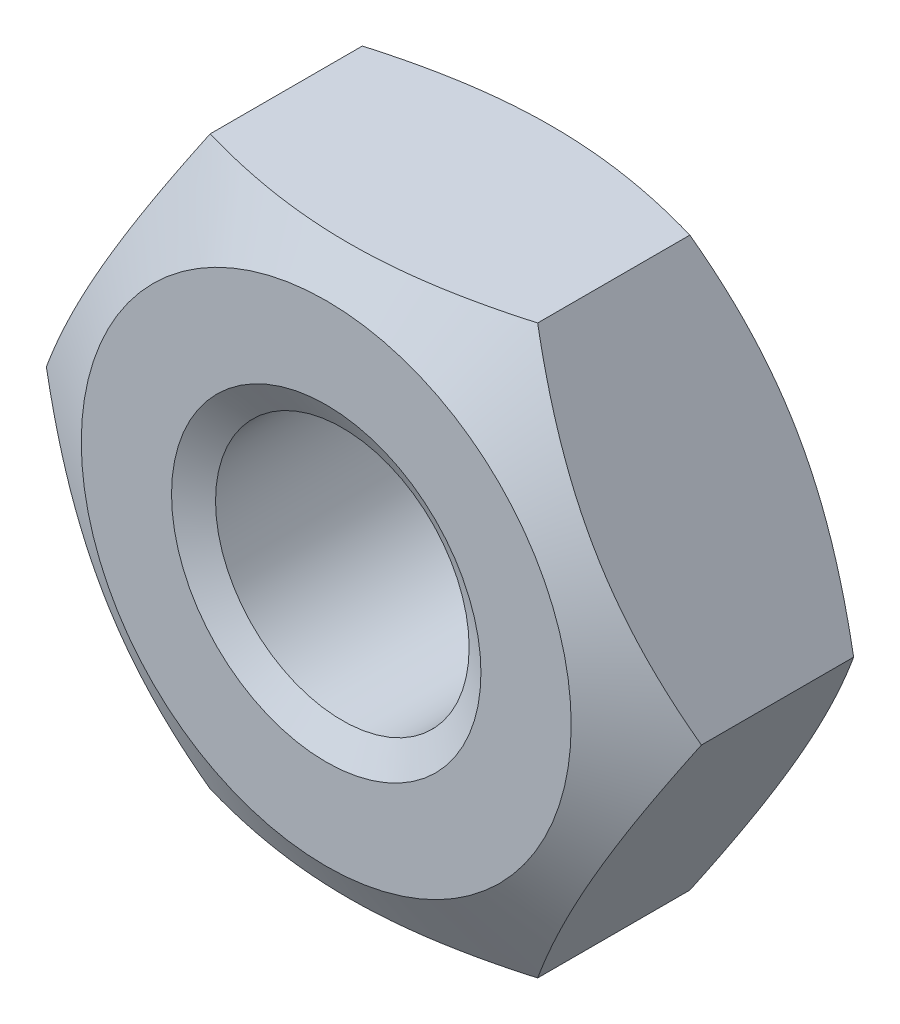
from build123d import *

# Parameters (mm, degrees)
SKETCH1_R               = 1.2295
BASENUT_DEPTH           = 2.4
ENDCHAMFER_SIZE         = 0.2705
ENDCHAMFER_SIZE2        = 0.156173248
ENDCHAMFER_PART_2_SIZE  = 0.2705
ENDCHAMFER_PART_2_SIZE2 = 0.156173248


with BuildPart() as part:
    # Sketch1 → BaseNut (new body)
    with BuildSketch(Plane.XY):
        Polygon((3.175426481, 0), (1.58771324, 2.75), (-1.58771324, 2.75), (-3.175426481, 0), (-1.58771324, -2.75), (1.58771324, -2.75), align=None)
        Circle(SKETCH1_R, mode=Mode.SUBTRACT)
    extrude(amount=-BASENUT_DEPTH)

    # Sketch2 → Double-Chamfer (revolve, cut)
    with BuildSketch(Plane(origin=(0, 0, 0), x_dir=(1, 0, 0), z_dir=(0, 1, 0))):
        Polygon((-3.175426481, 2.4), (-2.375, 2.4), (-3.175426481, 1.937873556), align=None)
        Polygon((-3.175426481, 0.462126444), (-3.175426481, 0), (-2.375, 0), align=None)
    revolve(axis=Axis((0, 0, -3.375940562), (0, 0, 1)), mode=Mode.SUBTRACT)

    # EndChamfer
    endchamfer_edges = [part.edges().sort_by_distance(p)[0] for p in [
        (-1.2295, 0, -2.4),
    ]]
    endchamfer_side = [part.faces().sort_by_distance(p)[0] for p in [
        (-1.2295, 0, -1.2),
    ]]
    chamfer(endchamfer_edges, length=ENDCHAMFER_SIZE, length2=ENDCHAMFER_SIZE2, reference=endchamfer_side[0])

    # EndChamfer part 2
    endchamfer_part_2_edges = [part.edges().sort_by_distance(p)[0] for p in [
        (-1.2295, 0, 0),
    ]]
    endchamfer_part_2_side = [part.faces().sort_by_distance(p)[0] for p in [
        (2.307824856, 0, 0),
    ]]
    chamfer(endchamfer_part_2_edges, length=ENDCHAMFER_PART_2_SIZE, length2=ENDCHAMFER_PART_2_SIZE2, reference=endchamfer_part_2_side[0])


solid = part.part
